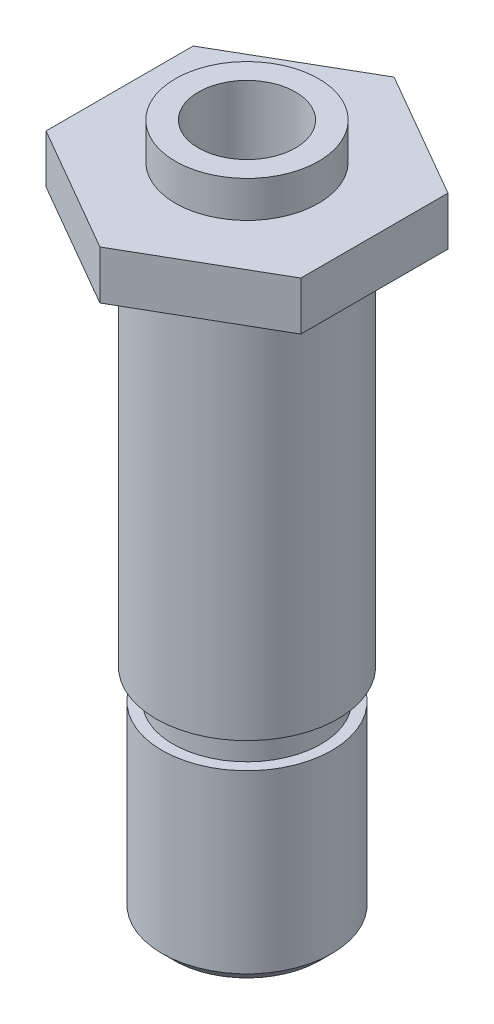
from build123d import *

# Parameters (mm, degrees)
EXTRUDE_1_DEPTH     = 4
SKETCH_2_R          = 5.9
EXTRUDE_2_DEPTH     = 3
SKETCH_3_R          = 7.5
EXTRUDE_3_DEPTH     = 50
SKETCH_4_R          = 4
CUT_EXTRUDE_1_DEPTH = 35
SKETCH_7_R          = 2
CUT_EXTRUDE_2_DEPTH = 58
CHAMFER_1_SIZE      = 1


with BuildPart() as part:
    # Эскиз1 → Бобышка-Вытянуть1 (new body)
    with BuildSketch(Plane(origin=(0, 0, 0), x_dir=(1, 0, 0), z_dir=(0, 1, 0))):
        Polygon((10.5, -6.062177826), (10.5, 6.062177826), (0, 12.124355653), (-10.5, 6.062177826), (-10.5, -6.062177826), (0, -12.124355653), align=None)
    extrude(amount=EXTRUDE_1_DEPTH)

    # Эскиз2 → Бобышка-Вытянуть2 (add)
    with BuildSketch(Plane(origin=(0, 4, 0), x_dir=(1, 0, 0), z_dir=(0, 1, 0))):
        Circle(SKETCH_2_R)
    extrude(amount=EXTRUDE_2_DEPTH)

    # Эскиз3 → Бобышка-Вытянуть3 (add)
    with BuildSketch(Plane.XZ):
        Circle(SKETCH_3_R)
    extrude(amount=EXTRUDE_3_DEPTH)

    # Эскиз4 → Вырез-Вытянуть1 (cut)
    with BuildSketch(Plane(origin=(0, 7, 0), x_dir=(1, 0, 0), z_dir=(0, 1, 0))):
        Circle(SKETCH_4_R)
    extrude(amount=-CUT_EXTRUDE_1_DEPTH, mode=Mode.SUBTRACT)

    # Эскиз6 → Вырез-Повернуть1 (revolve, cut)
    with BuildSketch(Plane(origin=(0, 0, 0), x_dir=(0, 0, -1), z_dir=(1, 0, 0))):
        Polygon((7.5, -50), (7.5, -32), (6.1, -32), (6.1, -34.5), (7, -34.5), (7, -50), align=None)
    revolve(axis=Axis((0, -50.526489701, 0), (0, 1, 0)), mode=Mode.SUBTRACT)

    # Эскиз7 → Вырез-Вытянуть2 (cut, through all)
    with BuildSketch(Plane.XZ.offset(50)):
        Circle(SKETCH_7_R)
    extrude(amount=-CUT_EXTRUDE_2_DEPTH, mode=Mode.SUBTRACT)

    # Фаска1
    chamfer_1_edges = [part.edges().sort_by_distance(p)[0] for p in [
        (0, -50, 7),
    ]]
    chamfer(chamfer_1_edges, length=CHAMFER_1_SIZE)


solid = part.part
